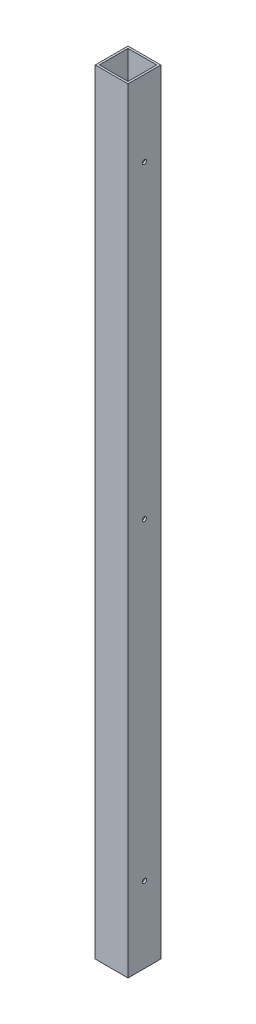
from build123d import *

# Parameters (mm, degrees)
SKETCH1_W           = 50.8
SKETCH1_H           = 50.8
SKETCH1_W_2         = 44.45
SKETCH1_H_2         = 44.45
BOSS_EXTRUDE1_DEPTH = 1200.15
SKETCH2_R           = 3.302
CUT_EXTRUDE1_DEPTH  = 50.8


with BuildPart() as part:
    # Sketch1 → Boss-Extrude1 (new body)
    with BuildSketch(Plane(origin=(0, 0, 0), x_dir=(1, 0, 0), z_dir=(0, 1, 0))):
        Rectangle(SKETCH1_W, SKETCH1_H)
        Rectangle(SKETCH1_W_2, SKETCH1_H_2, mode=Mode.SUBTRACT)
    extrude(amount=BOSS_EXTRUDE1_DEPTH)

    # Sketch2 → Cut-Extrude1 (cut)
    with BuildSketch(Plane(origin=(25.4, 0, 0), x_dir=(0, 0, -1), z_dir=(1, 0, 0))):
        with Locations((0, 603.25)):
            Circle(SKETCH2_R)
        with Locations((0, 117.602)):
            Circle(SKETCH2_R)
        with Locations((0, 1082.548)):
            Circle(SKETCH2_R)
    extrude(amount=-CUT_EXTRUDE1_DEPTH, mode=Mode.SUBTRACT)


solid = part.part
